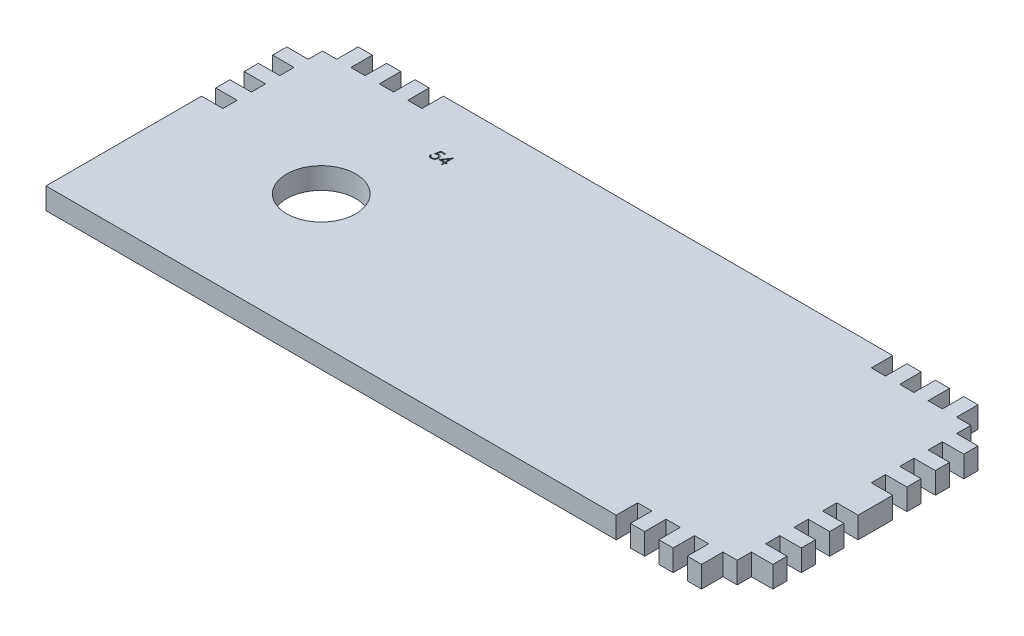
from build123d import *

# Parameters (mm, degrees)
SKETCH1_R           = 10
BOSS_EXTRUDE1_DEPTH = 6.2
CUT_EXTRUDE1_DEPTH  = 1


with BuildPart() as part:
    # Sketch1 → Boss-Extrude1 (new body)
    with BuildSketch(Plane(origin=(0, 0, 0), x_dir=(1, 0, 0), z_dir=(0, 1, 0))):
        Polygon((0, 45.002), (0, 0), (165.002, 0), (165.002, 6.2), (169.116, 6.2), (169.116, 0), (173.23, 0), (173.23, 6.2), (177.344, 6.2), (177.344, 0), (181.458, 0), (181.458, 6.2), (185.572, 6.2), (185.572, 0), (189.686, 0), (189.686, 6.2), (193.8, 6.2), (193.8, 10.314), (200, 10.314), (200, 14.428), (193.8, 14.428), (193.8, 18.542), (200, 18.542), (200, 22.656), (193.8, 22.656), (193.8, 26.77), (200, 26.77), (200, 30.884), (193.8, 30.884), (193.8, 34.998), (200, 34.998), (200, 45.002), (193.8, 45.002), (193.8, 49.116), (200, 49.116), (200, 53.23), (193.8, 53.23), (193.8, 57.344), (200, 57.344), (200, 61.458), (193.8, 61.458), (193.8, 65.572), (200, 65.572), (200, 69.686), (193.8, 69.686), (193.8, 73.8), (189.686, 73.8), (189.686, 80), (185.576, 80), (185.576, 73.8), (181.462, 73.8), (181.462, 80), (177.348, 80), (177.348, 73.8), (173.234, 73.8), (173.234, 80), (169.12, 80), (169.12, 73.8), (165.006, 73.8), (165.006, 80), (34.998, 80), (34.998, 73.8), (30.884, 73.8), (30.884, 80), (26.77, 80), (26.77, 73.8), (22.656, 73.8), (22.656, 80), (18.542, 80), (18.542, 73.8), (14.428, 73.8), (14.428, 80), (10.314, 80), (10.314, 73.8), (6.2, 73.8), (6.2, 69.686), (0, 69.686), (0, 65.572), (6.2, 65.572), (6.2, 61.458), (0, 61.458), (0, 57.344), (6.2, 57.344), (6.2, 53.23), (0, 53.23), (0, 49.116), (6.2, 49.116), (6.2, 45.002), align=None)
        with Locations((41.81119745, 37.836428286)):
            Circle(SKETCH1_R, mode=Mode.SUBTRACT)
    extrude(amount=BOSS_EXTRUDE1_DEPTH)

    # Sketch2 → Cut-Extrude1 (cut)
    with BuildSketch(Plane(origin=(0, 6.2, 0), x_dir=(1, 0, 0), z_dir=(0, 1, 0))):
        with BuildLine():
            Line((49.75994289, 65.855432978), (49.75994289, 65.529791952))
            Line((49.75994289, 65.529791952), (48.679984958, 65.529791952))
            Line((48.679984958, 65.529791952), (48.508896216, 64.694700807))
            add(Edge.make_bspline(
                [(48.508896216, 64.694700807), (48.542511188, 64.703981125), (48.607634879, 64.721960273), (48.70375561, 64.74192265), (48.795007109, 64.753956303), (48.854221195, 64.755599421), (48.882874581, 64.756394517)],
                knots=[0, 0, 0, 0, 0.000104595, 0.000202637, 0.000294305, 0.000380252, 0.000380252, 0.000380252, 0.000380252], degree=3))
            add(Edge.make_bspline(
                [(48.882874581, 64.756394517), (48.918329116, 64.755627132), (48.988041591, 64.754118262), (49.090039779, 64.739629513), (49.187406046, 64.716824019), (49.279936768, 64.684964689), (49.367803124, 64.644225145), (49.450196698, 64.593334485), (49.528354233, 64.533886392), (49.600873586, 64.465537702), (49.666663495, 64.39031595), (49.724508357, 64.309437024), (49.773641564, 64.22368693), (49.813157391, 64.132246378), (49.844711752, 64.036126289), (49.865713918, 63.934315303), (49.879699076, 63.82777308), (49.881261526, 63.754925363), (49.882058275, 63.71777773)],
                knots=[0, 0, 0, 0, 0.000106308, 0.000209029, 0.000308378, 0.000405929, 0.000502102, 0.000598312, 0.00069588, 0.000796219, 0.000896736, 0.000995218, 0.001094066, 0.001192613, 0.001293582, 0.001396995, 0.001504047, 0.001615439, 0.001615439, 0.001615439, 0.001615439], degree=3))
            add(Edge.make_bspline(
                [(49.882058275, 63.71777773), (49.881454957, 63.691904001), (49.880256474, 63.640506205), (49.874161755, 63.564175395), (49.862427212, 63.489460539), (49.846672205, 63.416351726), (49.826223012, 63.344987367), (49.801467942, 63.275163196), (49.771172974, 63.207313802), (49.737943083, 63.140797194), (49.700526636, 63.07711712), (49.65899899, 63.01756411), (49.61512458, 62.961244798), (49.567915609, 62.908763197), (49.516933277, 62.860464174), (49.462795022, 62.81606109), (49.405932841, 62.774803026), (49.345467014, 62.738364735), (49.282744904, 62.704834053), (49.216860736, 62.677326273), (49.149314243, 62.652733151), (49.079133249, 62.633130222), (49.006476719, 62.617769976), (48.931224887, 62.607337289), (48.853772422, 62.599738663), (48.801271518, 62.599262997), (48.774751584, 62.599022722)],
                knots=[0, 0, 0, 0, 7.7636e-05, 0.000154223, 0.000229512, 0.000304362, 0.000378447, 0.000452077, 0.000526407, 0.000601214, 0.00067506, 0.000747747, 0.00081887, 0.000889121, 0.000959302, 0.001029336, 0.001099058, 0.00116985, 0.001240974, 0.00131221, 0.00138383, 0.001456517, 0.001530612, 0.001606437, 0.001684346, 0.001763871, 0.001763871, 0.001763871, 0.001763871], degree=3))
            add(Edge.make_bspline(
                [(48.774751584, 62.599022722), (48.74311572, 62.59964941), (48.680875895, 62.600882346), (48.589689381, 62.613780544), (48.501955417, 62.632253525), (48.418380254, 62.660044998), (48.338214893, 62.694867759), (48.262538571, 62.738878857), (48.189417617, 62.788752758), (48.121824555, 62.847608507), (48.059090081, 62.911939162), (48.002932033, 62.981750736), (47.952918003, 63.055891016), (47.909848904, 63.134720055), (47.873111413, 63.218030723), (47.844250674, 63.306135159), (47.820956738, 63.39857302), (47.811102063, 63.462212276), (47.806096737, 63.494535542)],
                knots=[0, 0, 0, 0, 9.4843e-05, 0.000186593, 0.000275792, 0.000363484, 0.000450342, 0.000537514, 0.000625728, 0.000715478, 0.000805885, 0.000894984, 0.00098389, 0.001073836, 0.001164117, 0.001256635, 0.001351658, 0.001449737, 0.001449737, 0.001449737, 0.001449737], degree=3))
            Line((47.806096737, 63.494535542), (48.091032634, 63.494535542))
            add(Edge.make_bspline(
                [(48.091032634, 63.494535542), (48.09804354, 63.464258332), (48.11151889, 63.406063852), (48.141096962, 63.32430185), (48.177261006, 63.25144084), (48.220263522, 63.186517003), (48.271562478, 63.129903127), (48.330099889, 63.079450507), (48.395729609, 63.033934497), (48.468657753, 62.995995272), (48.545595332, 62.963638617), (48.626119873, 62.942092437), (48.708038815, 62.926942341), (48.763445623, 62.925425815), (48.791288043, 62.924663747)],
                knots=[0, 0, 0, 0, 9.3172e-05, 0.000179081, 0.000260145, 0.000336703, 0.000411917, 0.000488562, 0.000568128, 0.000650923, 0.00073478, 0.000817953, 0.000900557, 0.000983994, 0.000983994, 0.000983994, 0.000983994], degree=3))
            add(Edge.make_bspline(
                [(48.791288043, 62.924663747), (48.818464632, 62.92540831), (48.871975557, 62.92687436), (48.950725887, 62.938158321), (49.026756137, 62.955536975), (49.099316096, 62.981544629), (49.169675493, 63.013153767), (49.236054556, 63.053716729), (49.300373595, 63.100398317), (49.360633401, 63.153880403), (49.415823473, 63.212817197), (49.464587955, 63.275843118), (49.505207012, 63.343077686), (49.539437239, 63.413356903), (49.565429874, 63.487451023), (49.583972765, 63.565012803), (49.594861254, 63.646233821), (49.59635911, 63.701632409), (49.597122378, 63.729862065)],
                knots=[0, 0, 0, 0, 8.15e-05, 0.000160473, 0.000238226, 0.000315066, 0.000391338, 0.000469218, 0.000547964, 0.000629516, 0.000710512, 0.000789892, 0.000868102, 0.000945761, 0.001024012, 0.00110315, 0.001184644, 0.001269321, 0.001269321, 0.001269321, 0.001269321], degree=3))
            add(Edge.make_bspline(
                [(49.597122378, 63.729862065), (49.596525043, 63.755330782), (49.595355845, 63.805182173), (49.585803113, 63.878115739), (49.569187002, 63.947124856), (49.546123911, 64.012542768), (49.516841786, 64.074431176), (49.481058346, 64.132853952), (49.438102049, 64.187041073), (49.389032979, 64.237017889), (49.33527747, 64.283141454), (49.275910647, 64.322460733), (49.212174856, 64.355538715), (49.144838005, 64.384084685), (49.072298418, 64.40458679), (48.995992616, 64.419979086), (48.915096602, 64.428883022), (48.859787478, 64.430118449), (48.831357153, 64.430753491)],
                knots=[0, 0, 0, 0, 7.6388e-05, 0.000149519, 0.000220172, 0.000288967, 0.000357247, 0.000425206, 0.000494043, 0.000564207, 0.000635056, 0.000706145, 0.000777268, 0.000850264, 0.000925136, 0.001002969, 0.001083601, 0.001168886, 0.001168886, 0.001168886, 0.001168886], degree=3))
            add(Edge.make_bspline(
                [(48.831357153, 64.430753491), (48.806747339, 64.430226812), (48.755934317, 64.429139353), (48.677990038, 64.421132459), (48.596082547, 64.408215385), (48.510525826, 64.390447861), (48.421062936, 64.367196813), (48.327882673, 64.339334373), (48.230789117, 64.306022274), (48.165368038, 64.280865194), (48.131737762, 64.267932978)],
                knots=[0, 0, 0, 0, 7.3822e-05, 0.000152423, 0.000234822, 0.000322511, 0.00041445, 0.000512043, 0.000614219, 0.000722306, 0.000722306, 0.000722306, 0.000722306], degree=3))
            Line((48.131737762, 64.267932978), (48.457378788, 65.855432978))
            Line((48.457378788, 65.855432978), (49.75994289, 65.855432978))
        make_face()
        Polygon((51.940847338, 65.936843234), (51.998724942, 65.936843234), (51.998724942, 63.738766311), (52.365071096, 63.738766311), (52.365071096, 63.413125286), (51.998724942, 63.413125286), (51.998724942, 62.680432978), (51.713789044, 62.680432978), (51.713789044, 63.413125286), (50.207699301, 63.413125286), align=None)
        Polygon((51.713789044, 63.738766311), (51.713789044, 65.117652529), (50.767394814, 63.738766311), align=None, mode=Mode.SUBTRACT)
    extrude(amount=-CUT_EXTRUDE1_DEPTH, mode=Mode.SUBTRACT)


solid = part.part
